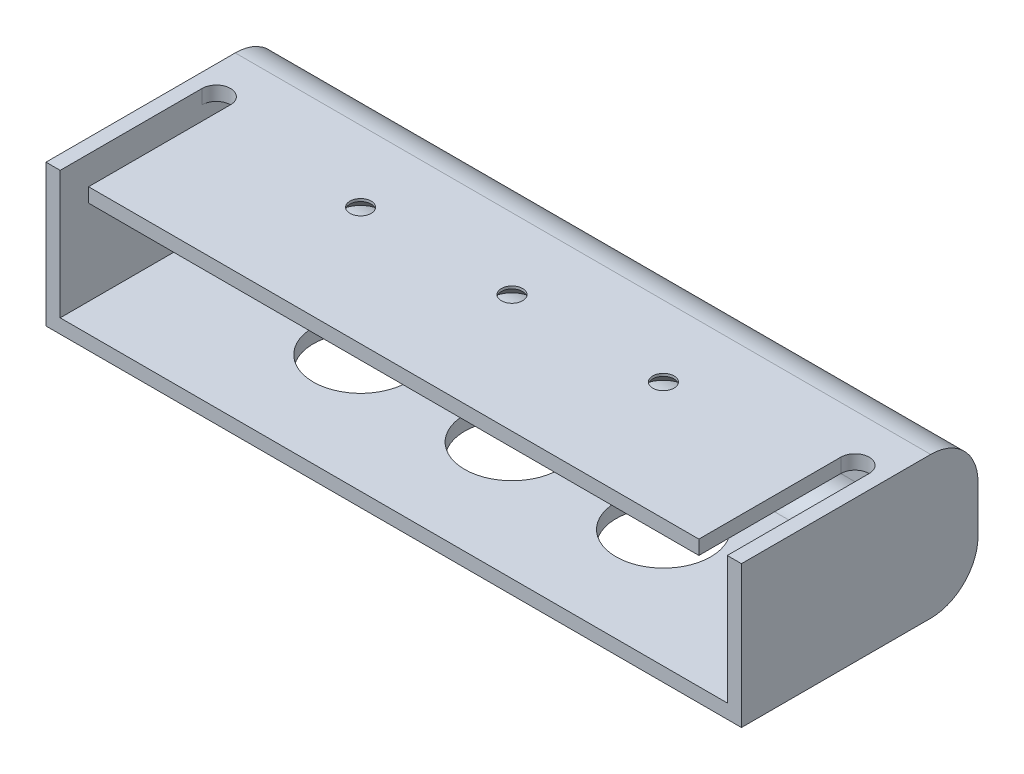
from build123d import *

# Parameters (mm, degrees)
SKETCH1_W                                    = 147
SKETCH1_H                                    = 50
BOSS_EXTRUDE1_DEPTH                          = 30
FILLET1_R                                    = 10
SHELL1_T                                     = -3
CUT_EXTRUDE1_DEPTH                           = 3
CSK_FOR_M4_COUNTERSUNK_FLAT_HEAD_SCR_2_COUNT = 2
CSK_FOR_M4_COUNTERSUNK_FLAT_HEAD_SCR_2_PITCH = 32
CSK_FOR_M4_COUNTERSUNK_FLAT_HEAD_SCR_3_COUNT = 2
CSK_FOR_M4_COUNTERSUNK_FLAT_HEAD_SCR_3_PITCH = 64
CUT_EXTRUDE2_REACH                           = 32
SKETCH5_R                                    = 10


with BuildPart() as part:
    # Sketch1 → Boss-Extrude1 (new body)
    with BuildSketch(Plane(origin=(0, 0, 0), x_dir=(1, 0, 0), z_dir=(0, 1, 0))):
        Rectangle(SKETCH1_W, SKETCH1_H)
    extrude(amount=BOSS_EXTRUDE1_DEPTH)

    # Fillet1
    fillet1_edges = [part.edges().sort_by_distance(p)[0] for p in [
        (0, 0, -25),
        (0, 30, -25),
    ]]
    fillet(fillet1_edges, radius=FILLET1_R)

    # Shell1
    shell1_openings = [part.faces().sort_by_distance(p)[0] for p in [
        (0, 15, 25),
    ]]
    offset(amount=SHELL1_T, openings=shell1_openings, kind=Kind.INTERSECTION)

    # Sketch2 → Cut-Extrude1 (cut)
    with BuildSketch(Plane(origin=(0, 30, 0), x_dir=(1, 0, 0), z_dir=(0, 1, 0))):
        with BuildLine():
            Line((-70.5, -25), (-70.5, 5))
            ThreePointArc((-70.5, 5), (-67.5, 8), (-64.5, 5))
            Line((-64.5, 5), (-64.5, -25))
            Line((-64.5, -25), (-70.5, -25))
        make_face()
    cut_extrude1 = extrude(amount=-CUT_EXTRUDE1_DEPTH, mode=Mode.SUBTRACT)

    # Mirror1: Cut-Extrude1 across plane
    add(cut_extrude1.mirror(Plane(origin=(0, 0, 0), x_dir=(0, 0, 1), z_dir=(1, 0, 0))), mode=Mode.SUBTRACT)

    # Sketch3 → CSK for M4 Countersunk Flat Head Screw1 (revolve, cut)
    with BuildSketch(Plane(origin=(-32, 27, 0), x_dir=(0, 0, -1), z_dir=(1, 0, 0))):
        Polygon((0, 0), (0, 3), (2.25, 3), (2.25, 2.45), (4.7, 0), align=None)
    csk_for_m4_countersunk_flat_head_screw1 = revolve(axis=Axis((-32, 20.65, 0), (0, 1, 0)), mode=Mode.SUBTRACT)

    # CSK for M4 Countersunk Flat Head Scr 2: CSK for M4 Countersunk Flat Head Screw1 ×2
    with Locations(*[(i * CSK_FOR_M4_COUNTERSUNK_FLAT_HEAD_SCR_2_PITCH, 0, 0) for i in range(1, CSK_FOR_M4_COUNTERSUNK_FLAT_HEAD_SCR_2_COUNT)]):
        add(csk_for_m4_countersunk_flat_head_screw1, mode=Mode.SUBTRACT)

    # CSK for M4 Countersunk Flat Head Scr 3: CSK for M4 Countersunk Flat Head Screw1 ×2
    with Locations(*[(i * CSK_FOR_M4_COUNTERSUNK_FLAT_HEAD_SCR_3_PITCH, 0, 0) for i in range(1, CSK_FOR_M4_COUNTERSUNK_FLAT_HEAD_SCR_3_COUNT)]):
        add(csk_for_m4_countersunk_flat_head_screw1, mode=Mode.SUBTRACT)

    # Sketch5 → Cut-Extrude2 (cut, up to next)
    with BuildSketch(Plane.XZ, mode=Mode.PRIVATE) as cut_extrude2_sk1:
        Circle(SKETCH5_R)
    cut_extrude2_tool1 = extrude(cut_extrude2_sk1.sketch, amount=-CUT_EXTRUDE2_REACH, mode=Mode.PRIVATE) & part.part
    add(cut_extrude2_tool1.solids().sort_by_distance((0, 0, 0))[0], mode=Mode.SUBTRACT)
    # Sketch5 → Cut-Extrude2 (cut, up to next)
    with BuildSketch(Plane.XZ, mode=Mode.PRIVATE) as cut_extrude2_sk2:
        with Locations((-32, 0)):
            Circle(SKETCH5_R)
    cut_extrude2_tool2 = extrude(cut_extrude2_sk2.sketch, amount=-CUT_EXTRUDE2_REACH, mode=Mode.PRIVATE) & part.part
    add(cut_extrude2_tool2.solids().sort_by_distance((-32, 0, 0))[0], mode=Mode.SUBTRACT)
    # Sketch5 → Cut-Extrude2 (cut, up to next)
    with BuildSketch(Plane.XZ, mode=Mode.PRIVATE) as cut_extrude2_sk3:
        with Locations((32, 0)):
            Circle(SKETCH5_R)
    cut_extrude2_tool3 = extrude(cut_extrude2_sk3.sketch, amount=-CUT_EXTRUDE2_REACH, mode=Mode.PRIVATE) & part.part
    add(cut_extrude2_tool3.solids().sort_by_distance((32, 0, 0))[0], mode=Mode.SUBTRACT)


solid = part.part
